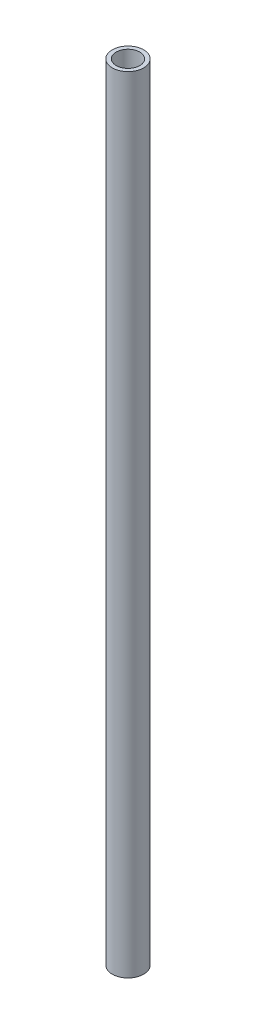
from build123d import *

# Parameters (mm, degrees)
SKETCH_1_R      = 4
SKETCH_1_R_2    = 3
EXTRUDE_1_DEPTH = 200


with BuildPart() as part:
    # Эскиз1 → Бобышка-Вытянуть1 (new body)
    with BuildSketch(Plane(origin=(0, 0, 0), x_dir=(1, 0, 0), z_dir=(0, 1, 0))):
        Circle(SKETCH_1_R)
        Circle(SKETCH_1_R_2, mode=Mode.SUBTRACT)
    extrude(amount=EXTRUDE_1_DEPTH)


solid = part.part
